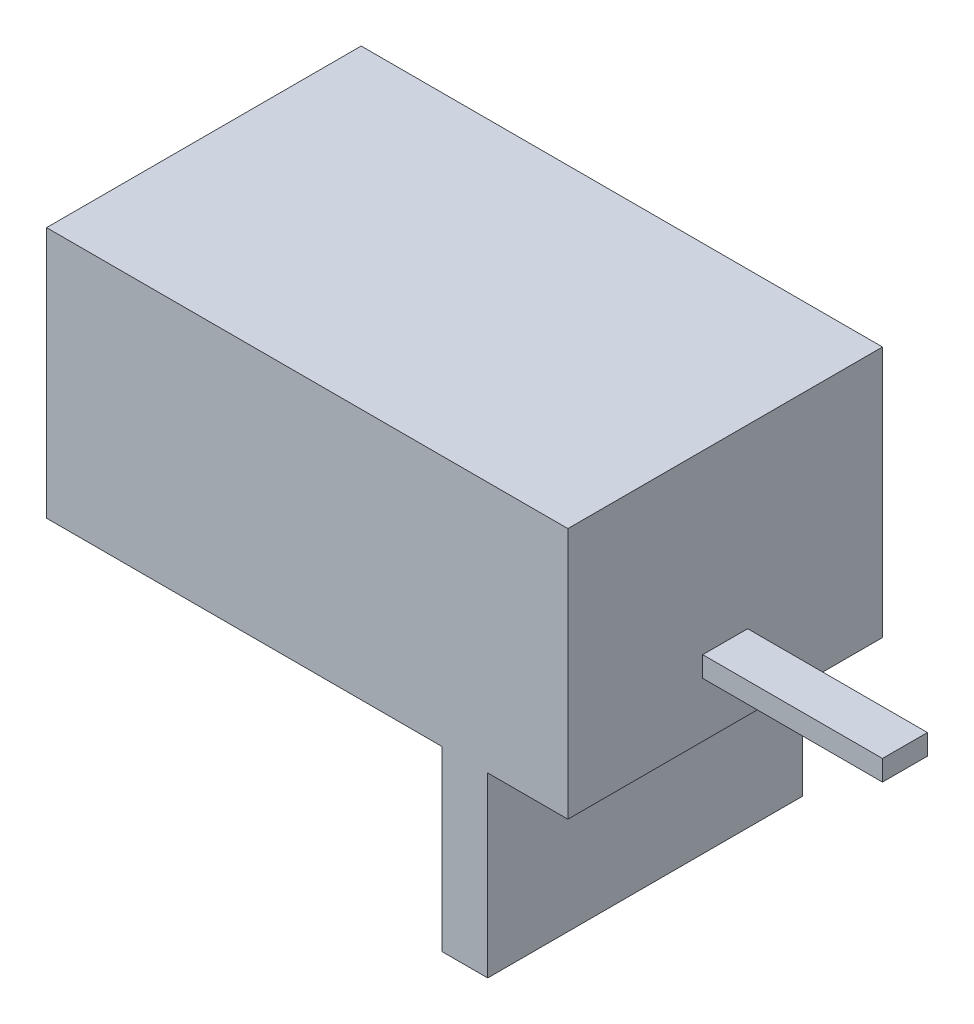
from build123d import *

# Parameters (mm, degrees)
SKETCH1_W           = 290
SKETCH1_H           = 175
BOSS_EXTRUDE1_DEPTH = 140
SKETCH2_W           = 25.4
SKETCH2_H           = 175
BOSS_EXTRUDE2_DEPTH = 98.8
SKETCH3_W           = 25
SKETCH3_H           = 11.396117448
BOSS_EXTRUDE3_DEPTH = 100


with BuildPart() as part:
    # Sketch1 → Boss-Extrude1 (new body)
    with BuildSketch(Plane(origin=(0, 0, 0), x_dir=(1, 0, 0), z_dir=(0, 1, 0))):
        Rectangle(SKETCH1_W, SKETCH1_H)
    extrude(amount=BOSS_EXTRUDE1_DEPTH)

    # Sketch2 → Boss-Extrude2 (add)
    with BuildSketch(Plane.XZ):
        with Locations((87.7, 0)):
            Rectangle(SKETCH2_W, SKETCH2_H)
    extrude(amount=BOSS_EXTRUDE2_DEPTH)

    # Sketch3 → Boss-Extrude3 (add)
    with BuildSketch(Plane(origin=(145, 0, 0), x_dir=(0, 0, -1), z_dir=(1, 0, 0))):
        with Locations((0, 36.066217011)):
            Rectangle(SKETCH3_W, SKETCH3_H)
    extrude(amount=BOSS_EXTRUDE3_DEPTH)


solid = part.part
